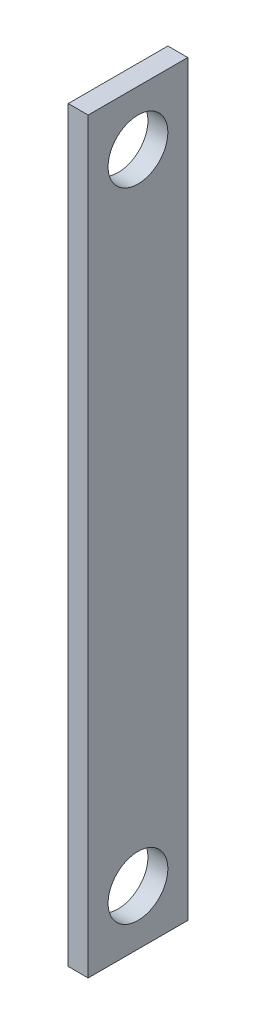
from build123d import *

# Parameters (mm, degrees)
SKETCH1_W           = 10
SKETCH1_H           = 75
BOSS_EXTRUDE1_DEPTH = 2
SKETCH2_R           = 3
CUT_EXTRUDE1_DEPTH  = 2


with BuildPart() as part:
    # Sketch1 → Boss-Extrude1 (new body)
    with BuildSketch(Plane(origin=(0, 0, 0), x_dir=(0, 0, -1), z_dir=(1, 0, 0))):
        Rectangle(SKETCH1_W, SKETCH1_H)
    extrude(amount=BOSS_EXTRUDE1_DEPTH)

    # Sketch2 → Cut-Extrude1 (cut)
    with BuildSketch(Plane(origin=(2, 0, 0), x_dir=(0, 0, -1), z_dir=(1, 0, 0))):
        with Locations((0, -32)):
            Circle(SKETCH2_R)
        with Locations((0, 32)):
            Circle(SKETCH2_R)
    extrude(amount=-CUT_EXTRUDE1_DEPTH, mode=Mode.SUBTRACT)


solid = part.part
